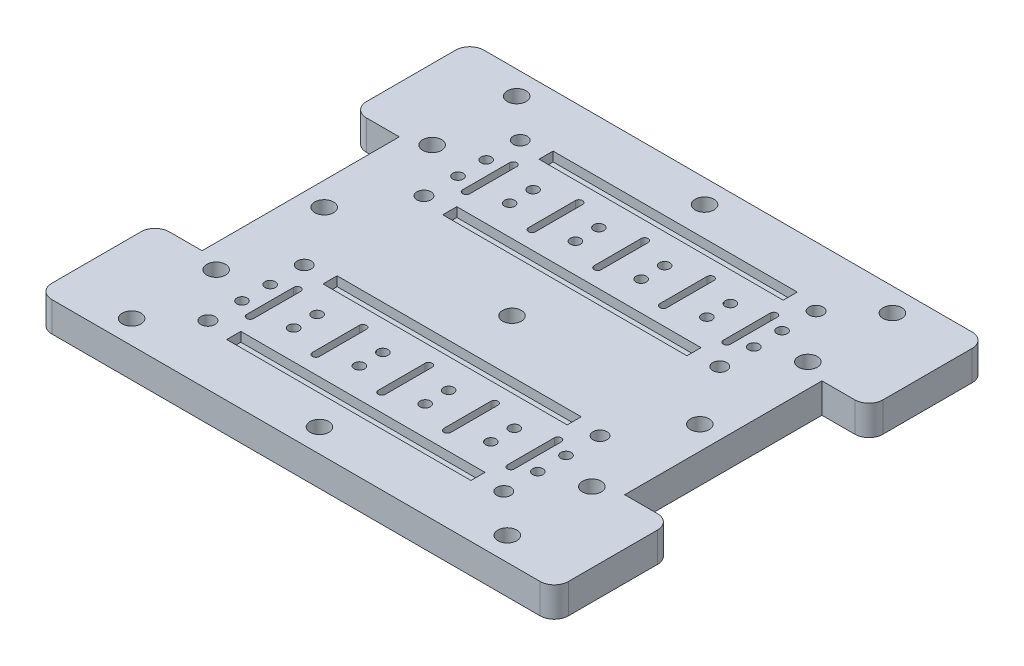
from build123d import *

# Parameters (mm, degrees)
SKETCH1_W               = 90
SKETCH1_H               = 46
SKETCH1_R               = 2
BOSS_EXTRUDE1_DEPTH     = 6.35
M2_CLEARANCE_HOLE1_D    = 2.2
CUT_EXTRUDE1_DEPTH      = 7.35
CUT_EXTRUDE2_DEPTH      = 7.35
SKETCH8_W               = 25
SKETCH8_H               = 6.35
BOSS_EXTRUDE2_DEPTH     = 10
FILLET1_R               = 3
MIRROR5_COPY_1_SKETCH_W = 90
MIRROR5_COPY_1_SKETCH_H = 46
MIRROR5_COPY_1_SKETCH_R = 2
MIRROR5_COPY_1_DEPTH    = 6.35
MIRROR5_COPY_2_D        = 2.2
MIRROR5_COPY_3_DEPTH    = 7.35
MIRROR5_COPY_4_DEPTH    = 7.35
MIRROR5_COPY_5_D        = 2.2
MIRROR5_COPY_6_DEPTH    = 7.35
MIRROR5_COPY_7_DEPTH    = 7.35
FILLET1_OF_MIRROR5_R    = 3
SKETCH9_R               = 2
CUT_EXTRUDE3_DEPTH      = 10
SKETCH10_R              = 2
CUT_EXTRUDE4_DEPTH      = 6.35
SKETCH12_R              = 1.5
CUT_EXTRUDE6_DEPTH      = 7.35
SKETCH11_W              = 52
SKETCH11_H              = 3
CUT_EXTRUDE7_DEPTH      = 2


with BuildPart() as part:
    # Sketch1 → Boss-Extrude1 (new body)
    with BuildSketch(Plane(origin=(0, 0, 0), x_dir=(1, 0, 0), z_dir=(0, 1, 0))):
        with Locations((45, 23)):
            Rectangle(SKETCH1_W, SKETCH1_H)
        with Locations((45, 5)):
            Circle(SKETCH1_R, mode=Mode.SUBTRACT)
        with Locations((5, 23)):
            Circle(SKETCH1_R, mode=Mode.SUBTRACT)
        with Locations((85, 23)):
            Circle(SKETCH1_R, mode=Mode.SUBTRACT)
    boss_extrude1 = extrude(amount=BOSS_EXTRUDE1_DEPTH)

    # M2 Clearance Hole1 (through all)
    with Locations(Plane(origin=(0, 6.35, 0), x_dir=(1, 0, 0), z_dir=(0, 1, 0))):
        with Locations((13.5, 26), (13.5, 20), (24, 25.5), (24, 20.5), (38, 25.5), (38, 20.5), (52, 25.5), (52, 20.5), (66, 25.5), (66, 20.5), (76.5, 26), (76.5, 20)):
            m2_clearance_hole1 = Hole(M2_CLEARANCE_HOLE1_D / 2)

    # Sketch6 → Cut-Extrude1 (cut, through all)
    with BuildSketch(Plane(origin=(0, 6.35, 0), x_dir=(1, 0, 0), z_dir=(0, 1, 0))):
        with BuildLine():
            Line((18, 28), (18, 18))
            ThreePointArc((18, 18), (17.25, 17.25), (16.5, 18))
            Line((16.5, 18), (16.5, 28))
            ThreePointArc((16.5, 28), (17.25, 28.75), (18, 28))
        make_face()
    cut_extrude1 = extrude(amount=-CUT_EXTRUDE1_DEPTH, mode=Mode.SUBTRACT)

    # Sketch7 → Cut-Extrude2 (cut, through all)
    with BuildSketch(Plane(origin=(0, 6.35, 0), x_dir=(1, 0, 0), z_dir=(0, 1, 0))):
        with BuildLine():
            Line((31.5, 28), (31.5, 18))
            ThreePointArc((31.5, 18), (30.75, 17.25), (30, 18))
            Line((30, 18), (30, 28))
            ThreePointArc((30, 28), (30.75, 28.75), (31.5, 28))
        make_face()
        with BuildLine():
            Line((44, 28), (44, 18))
            ThreePointArc((44, 18), (44.75, 17.25), (45.5, 18))
            Line((45.5, 18), (45.5, 28))
            ThreePointArc((45.5, 28), (44.75, 28.75), (44, 28))
        make_face()
        with BuildLine():
            Line((58, 28), (58, 18))
            ThreePointArc((58, 18), (58.75, 17.25), (59.5, 18))
            Line((59.5, 18), (59.5, 28))
            ThreePointArc((59.5, 28), (58.75, 28.75), (58, 28))
        make_face()
        with BuildLine():
            Line((73.5, 28), (73.5, 18))
            ThreePointArc((73.5, 18), (72.75, 17.25), (72, 18))
            Line((72, 18), (72, 28))
            ThreePointArc((72, 28), (72.75, 28.75), (73.5, 28))
        make_face()
    cut_extrude2 = extrude(amount=-CUT_EXTRUDE2_DEPTH, mode=Mode.SUBTRACT)

    # Mirror1: Boss-Extrude1, M2 Clearance Hole1, Cut-Extrude1, Cut-Extrude2 across plane
    add(boss_extrude1.mirror(Plane(origin=(0, 0, -46), x_dir=(1, 0, 0), z_dir=(0, 0, -1))))
    add(m2_clearance_hole1.mirror(Plane(origin=(0, 0, -46), x_dir=(1, 0, 0), z_dir=(0, 0, -1))), mode=Mode.SUBTRACT)
    add(cut_extrude1.mirror(Plane(origin=(0, 0, -46), x_dir=(1, 0, 0), z_dir=(0, 0, -1))), mode=Mode.SUBTRACT)
    add(cut_extrude2.mirror(Plane(origin=(0, 0, -46), x_dir=(1, 0, 0), z_dir=(0, 0, -1))), mode=Mode.SUBTRACT)

    # Sketch8 → Boss-Extrude2 (add)
    with BuildSketch(Plane(origin=(90, 0, 0), x_dir=(0, 0, -1), z_dir=(1, 0, 0))):
        with Locations((12.5, 3.175)):
            Rectangle(SKETCH8_W, SKETCH8_H)
        with Locations((79.5, 3.175)):
            Rectangle(SKETCH8_W, SKETCH8_H)
    boss_extrude2 = extrude(amount=BOSS_EXTRUDE2_DEPTH)

    # Fillet1
    fillet1_edges = [part.edges().sort_by_distance(p)[0] for p in [
        (100, 3.175, 0),
        (100, 3.175, -25),
        (100, 3.175, -92),
        (100, 3.175, -67),
    ]]
    fillet(fillet1_edges, radius=FILLET1_R)

    # Mirror5: Boss-Extrude1, Boss-Extrude2 across plane
    add(boss_extrude1.mirror(Plane.ZY.offset(-45)))
    add(boss_extrude2.mirror(Plane.ZY.offset(-45)))

    # Mirror5 copy 1 sketch → Mirror5 copy 1 (add)
    with BuildSketch(Plane(origin=(90, 0, -92), x_dir=(-1, 0, 0), z_dir=(0, 1, 0))):
        with Locations((45, 23)):
            Rectangle(MIRROR5_COPY_1_SKETCH_W, MIRROR5_COPY_1_SKETCH_H)
        with Locations((45, 5)):
            Circle(MIRROR5_COPY_1_SKETCH_R, mode=Mode.SUBTRACT)
        with Locations((5, 23)):
            Circle(MIRROR5_COPY_1_SKETCH_R, mode=Mode.SUBTRACT)
        with Locations((85, 23)):
            Circle(MIRROR5_COPY_1_SKETCH_R, mode=Mode.SUBTRACT)
    extrude(amount=MIRROR5_COPY_1_DEPTH)

    # Mirror5 copy 2 (through all)
    with Locations(Plane(origin=(90, 6.35, -92), x_dir=(-1, 0, 0), z_dir=(0, 1, 0))):
        with Locations((13.5, 26), (13.5, 20), (24, 25.5), (24, 20.5), (38, 25.5), (38, 20.5), (52, 25.5), (52, 20.5), (66, 25.5), (66, 20.5), (76.5, 26), (76.5, 20)):
            Hole(MIRROR5_COPY_2_D / 2)

    # Mirror5 copy 3 sketch → Mirror5 copy 3 (cut, through all)
    with BuildSketch(Plane(origin=(90, 6.35, -92), x_dir=(-1, 0, 0), z_dir=(0, 1, 0))):
        with BuildLine():
            Line((18, 28), (18, 18))
            ThreePointArc((18, 18), (17.25, 17.25), (16.5, 18))
            Line((16.5, 18), (16.5, 28))
            ThreePointArc((16.5, 28), (17.25, 28.75), (18, 28))
        make_face()
    extrude(amount=-MIRROR5_COPY_3_DEPTH, mode=Mode.SUBTRACT)

    # Mirror5 copy 4 sketch → Mirror5 copy 4 (cut, through all)
    with BuildSketch(Plane(origin=(90, 6.35, -92), x_dir=(-1, 0, 0), z_dir=(0, 1, 0))):
        with BuildLine():
            Line((31.5, 28), (31.5, 18))
            ThreePointArc((31.5, 18), (30.75, 17.25), (30, 18))
            Line((30, 18), (30, 28))
            ThreePointArc((30, 28), (30.75, 28.75), (31.5, 28))
        make_face()
        with BuildLine():
            Line((44, 28), (44, 18))
            ThreePointArc((44, 18), (44.75, 17.25), (45.5, 18))
            Line((45.5, 18), (45.5, 28))
            ThreePointArc((45.5, 28), (44.75, 28.75), (44, 28))
        make_face()
        with BuildLine():
            Line((58, 28), (58, 18))
            ThreePointArc((58, 18), (58.75, 17.25), (59.5, 18))
            Line((59.5, 18), (59.5, 28))
            ThreePointArc((59.5, 28), (58.75, 28.75), (58, 28))
        make_face()
        with BuildLine():
            Line((73.5, 28), (73.5, 18))
            ThreePointArc((73.5, 18), (72.75, 17.25), (72, 18))
            Line((72, 18), (72, 28))
            ThreePointArc((72, 28), (72.75, 28.75), (73.5, 28))
        make_face()
    extrude(amount=-MIRROR5_COPY_4_DEPTH, mode=Mode.SUBTRACT)

    # Mirror5 copy 5 (through all)
    with Locations(Plane(origin=(90, 6.35, 0), x_dir=(-1, 0, 0), z_dir=(0, 1, 0))):
        with Locations((13.5, -26), (13.5, -20), (24, -25.5), (24, -20.5), (38, -25.5), (38, -20.5), (52, -25.5), (52, -20.5), (66, -25.5), (66, -20.5), (76.5, -26), (76.5, -20)):
            Hole(MIRROR5_COPY_5_D / 2)

    # Mirror5 copy 6 sketch → Mirror5 copy 6 (cut, through all)
    with BuildSketch(Plane(origin=(90, 6.35, 0), x_dir=(-1, 0, 0), z_dir=(0, 1, 0))):
        with BuildLine():
            Line((18, -28), (18, -18))
            ThreePointArc((18, -18), (17.25, -17.25), (16.5, -18))
            Line((16.5, -18), (16.5, -28))
            ThreePointArc((16.5, -28), (17.25, -28.75), (18, -28))
        make_face()
    extrude(amount=-MIRROR5_COPY_6_DEPTH, mode=Mode.SUBTRACT)

    # Mirror5 copy 7 sketch → Mirror5 copy 7 (cut, through all)
    with BuildSketch(Plane(origin=(90, 6.35, 0), x_dir=(-1, 0, 0), z_dir=(0, 1, 0))):
        with BuildLine():
            Line((31.5, -28), (31.5, -18))
            ThreePointArc((31.5, -18), (30.75, -17.25), (30, -18))
            Line((30, -18), (30, -28))
            ThreePointArc((30, -28), (30.75, -28.75), (31.5, -28))
        make_face()
        with BuildLine():
            Line((44, -28), (44, -18))
            ThreePointArc((44, -18), (44.75, -17.25), (45.5, -18))
            Line((45.5, -18), (45.5, -28))
            ThreePointArc((45.5, -28), (44.75, -28.75), (44, -28))
        make_face()
        with BuildLine():
            Line((58, -28), (58, -18))
            ThreePointArc((58, -18), (58.75, -17.25), (59.5, -18))
            Line((59.5, -18), (59.5, -28))
            ThreePointArc((59.5, -28), (58.75, -28.75), (58, -28))
        make_face()
        with BuildLine():
            Line((73.5, -28), (73.5, -18))
            ThreePointArc((73.5, -18), (72.75, -17.25), (72, -18))
            Line((72, -18), (72, -28))
            ThreePointArc((72, -28), (72.75, -28.75), (73.5, -28))
        make_face()
    extrude(amount=-MIRROR5_COPY_7_DEPTH, mode=Mode.SUBTRACT)

    # Fillet1 of Mirror5
    fillet1_of_mirror5_edges = [part.edges().sort_by_distance(p)[0] for p in [
        (-10, 3.175, 0),
        (-10, 3.175, -25),
        (-10, 3.175, -92),
        (-10, 3.175, -67),
    ]]
    fillet(fillet1_of_mirror5_edges, radius=FILLET1_OF_MIRROR5_R)

    # Sketch9 → Cut-Extrude3 (cut)
    with BuildSketch(Plane(origin=(0, 6.35, 0), x_dir=(1, 0, 0), z_dir=(0, 1, 0))):
        with Locations((5, 5)):
            Circle(SKETCH9_R)
        with Locations((85, 5)):
            Circle(SKETCH9_R)
        with Locations((85, 87)):
            Circle(SKETCH9_R)
        with Locations((5, 87)):
            Circle(SKETCH9_R)
    extrude(amount=-CUT_EXTRUDE3_DEPTH, mode=Mode.SUBTRACT)

    # Sketch10 → Cut-Extrude4 (cut)
    with BuildSketch(Plane.XZ):
        with Locations((85, -46)):
            Circle(SKETCH10_R)
        with Locations((45, -46)):
            Circle(SKETCH10_R)
        with Locations((5, -46)):
            Circle(SKETCH10_R)
    extrude(amount=-CUT_EXTRUDE4_DEPTH, mode=Mode.SUBTRACT)

    # Sketch12 → Cut-Extrude6 (cut, through all)
    with BuildSketch(Plane(origin=(0, 6.35, 0), x_dir=(1, 0, 0), z_dir=(0, 1, 0))):
        with Locations((13.5, 12.75)):
            Circle(SKETCH12_R)
        with Locations((13.5, 33.25)):
            Circle(SKETCH12_R)
        with Locations((76.5, 33.25)):
            Circle(SKETCH12_R)
        with Locations((76.5, 12.75)):
            Circle(SKETCH12_R)
    cut_extrude6 = extrude(amount=-CUT_EXTRUDE6_DEPTH, mode=Mode.SUBTRACT)

    # Mirror7: Cut-Extrude6 across plane
    add(cut_extrude6.mirror(Plane(origin=(0, 0, -46), x_dir=(1, 0, 0), z_dir=(0, 0, -1))), mode=Mode.SUBTRACT)

    # Sketch11 → Cut-Extrude7 (cut)
    with BuildSketch(Plane(origin=(0, 6.35, 0), x_dir=(1, 0, 0), z_dir=(0, 1, 0))):
        with Locations((45, 12.75)):
            Rectangle(SKETCH11_W, SKETCH11_H)
        with Locations((45, 33.25)):
            Rectangle(SKETCH11_W, SKETCH11_H)
        with Locations((45, 58.75)):
            Rectangle(SKETCH11_W, SKETCH11_H)
        with Locations((45, 79.25)):
            Rectangle(SKETCH11_W, SKETCH11_H)
    extrude(amount=-CUT_EXTRUDE7_DEPTH, mode=Mode.SUBTRACT)


solid = part.part
